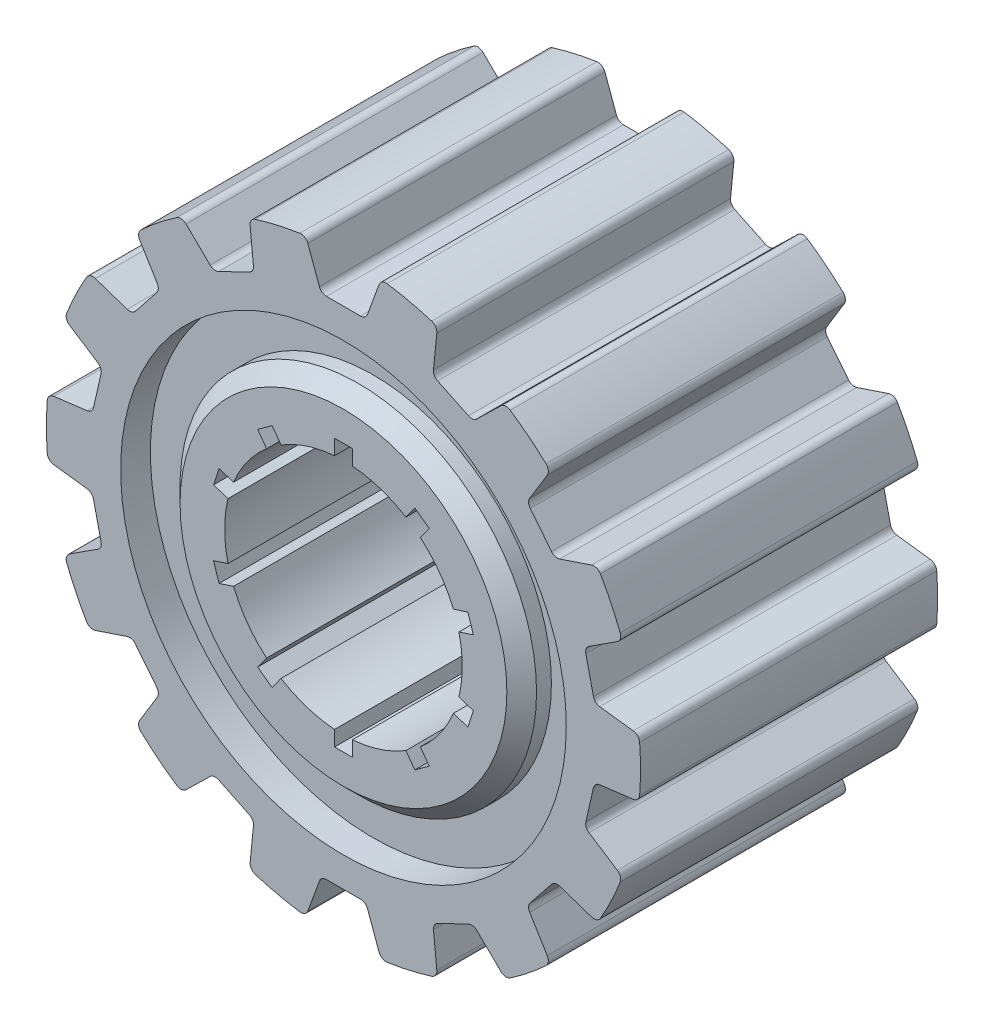
from build123d import *

# Parameters (mm, degrees)
SKETCH1_R           = 10
BOSS_EXTRUDE1_DEPTH = 10
CUT_EXTRUDE1_START  = -11
CUT_EXTRUDE1_DEPTH  = 12
CIRPATTERN1_COUNT   = 14
CUT_EXTRUDE2_START  = -4
SKETCH3_R           = 7.5
SKETCH3_R_2         = 6
CUT_EXTRUDE2_DEPTH  = 2
CHAMFER1_SIZE       = 0.5
CHAMFER2_SIZE       = 0.5
FILLET1_R           = 0.25


with BuildPart() as part:
    # Sketch1 → Boss-Extrude1 (new body)
    with BuildSketch(Plane.XY):
        Circle(SKETCH1_R)
        with BuildLine():
            Line((2.887738734, 3.464240899), (2.402328537, 3.81691205))
            Line((2.402328537, 3.81691205), (2.101814002, 3.403289277))
            ThreePointArc((2.101814002, 3.403289277), (1.236067977, 3.804226065), (0.3, 3.988734135))
            Line((0.3, 3.988734135), (0.3, 4.5))
            Line((0.3, 4.5), (-0.3, 4.5))
            Line((-0.3, 4.5), (-0.3, 3.988734135))
            ThreePointArc((-0.3, 3.988734135), (-1.236067978, 3.804226065), (-2.101814002, 3.403289277))
            Line((-2.101814002, 3.403289277), (-2.402328537, 3.81691205))
            Line((-2.402328537, 3.81691205), (-2.887738734, 3.464240899))
            Line((-2.887738734, 3.464240899), (-2.587224198, 3.050618126))
            ThreePointArc((-2.587224198, 3.050618126), (-3.236067977, 2.351141009), (-3.700806493, 1.517903589))
            Line((-3.700806493, 1.517903589), (-4.187049225, 1.67589343))
            Line((-4.187049225, 1.67589343), (-4.372459422, 1.10525952))
            Line((-4.372459422, 1.10525952), (-3.886216689, 0.947269679))
            ThreePointArc((-3.886216689, 0.947269679), (-4, 0), (-3.886216689, -0.947269679))
            Line((-3.886216689, -0.947269679), (-4.372459422, -1.10525952))
            Line((-4.372459422, -1.10525952), (-4.187049225, -1.67589343))
            Line((-4.187049225, -1.67589343), (-3.700806493, -1.517903589))
            ThreePointArc((-3.700806493, -1.517903589), (-3.236067977, -2.351141009), (-2.587224198, -3.050618126))
            Line((-2.587224198, -3.050618126), (-2.887738734, -3.464240899))
            Line((-2.887738734, -3.464240899), (-2.402328537, -3.81691205))
            Line((-2.402328537, -3.81691205), (-2.101814002, -3.403289277))
            ThreePointArc((-2.101814002, -3.403289277), (-1.236067977, -3.804226065), (-0.3, -3.988734135))
            Line((-0.3, -3.988734135), (-0.3, -4.5))
            Line((-0.3, -4.5), (0.3, -4.5))
            Line((0.3, -4.5), (0.3, -3.988734135))
            ThreePointArc((0.3, -3.988734135), (1.236067978, -3.804226065), (2.101814002, -3.403289277))
            Line((2.101814002, -3.403289277), (2.402328537, -3.81691205))
            Line((2.402328537, -3.81691205), (2.887738734, -3.464240899))
            Line((2.887738734, -3.464240899), (2.587224198, -3.050618126))
            ThreePointArc((2.587224198, -3.050618126), (3.236067977, -2.351141009), (3.700806493, -1.517903589))
            Line((3.700806493, -1.517903589), (4.187049225, -1.67589343))
            Line((4.187049225, -1.67589343), (4.372459422, -1.10525952))
            Line((4.372459422, -1.10525952), (3.886216689, -0.947269679))
            ThreePointArc((3.886216689, -0.947269679), (4, 0), (3.886216689, 0.947269679))
            Line((3.886216689, 0.947269679), (4.372459422, 1.10525952))
            Line((4.372459422, 1.10525952), (4.187049225, 1.67589343))
            Line((4.187049225, 1.67589343), (3.700806493, 1.517903589))
            ThreePointArc((3.700806493, 1.517903589), (3.236067977, 2.351141009), (2.587224198, 3.050618126))
            Line((2.587224198, 3.050618126), (2.887738734, 3.464240899))
        make_face(mode=Mode.SUBTRACT)
    extrude(amount=BOSS_EXTRUDE1_DEPTH)

    # Sketch2 → Cut-Extrude1 (cut)
    with BuildSketch(Plane.XY.offset(10).offset(CUT_EXTRUDE1_START)):
        Polygon((-20.341084154, 62.326061337), (-1.266640021, 9.919456792), (-0.75, 8.5), (0.75, 8.5), (1.266640021, 9.919456792), (20.341084154, 62.326061337), (20.341084154, 173.86594871), (-20.341084154, 173.86594871), align=None)
    cut_extrude1 = extrude(amount=CUT_EXTRUDE1_DEPTH, mode=Mode.SUBTRACT)

    # CirPattern1: Cut-Extrude1 ×14 about axis
    cirpattern1_axis = Axis((0, 0, 0), (0, 0, 1))
    for i in range(1, CIRPATTERN1_COUNT):
        add(cut_extrude1.rotate(cirpattern1_axis, i * 360 / CIRPATTERN1_COUNT), mode=Mode.SUBTRACT)

    # Sketch3 → Cut-Extrude2 (cut, through all)
    with BuildSketch(Plane.XY.offset(5).offset(CUT_EXTRUDE2_START)):
        Circle(SKETCH3_R)
        Circle(SKETCH3_R_2, mode=Mode.SUBTRACT)
    cut_extrude2 = extrude(amount=-CUT_EXTRUDE2_DEPTH, mode=Mode.SUBTRACT)

    # Chamfer1
    chamfer1_edges = [part.edges().sort_by_distance(p)[0] for p in [
        (-6, 0, 0),
    ]]
    chamfer(chamfer1_edges, length=CHAMFER1_SIZE)

    # Mirror2: Cut-Extrude2 across plane
    add(cut_extrude2.mirror(Plane.XY.offset(5)), mode=Mode.SUBTRACT)

    # Chamfer2
    chamfer2_edges = [part.edges().sort_by_distance(p)[0] for p in [
        (-6, 0, 10),
    ]]
    chamfer(chamfer2_edges, length=CHAMFER2_SIZE)

    # Fillet1
    fillet1_edges = [part.edges().sort_by_distance(p)[0] for p in [
        (0.75, 8.5, 5),
        (-0.75, 8.5, 5),
        (-1.266640021, 9.919456792, 5),
        (1.266640021, 9.919456792, 5),
        (-3.162687777, 9.486696265, 5),
        (-5.445094229, 8.387547248, 5),
        (5.445094229, 8.387547248, 5),
        (3.162687777, 9.486696265, 5),
        (8.545080745, 5.194381104, 5),
        (6.965606473, 7.174979196, 5),
        (9.952609221, 0.972404078, 5),
        (9.38890138, 3.442169501, 5),
        (9.38890138, -3.442169501, 5),
        (9.952609221, -0.972404078, 5),
        (6.965606473, -7.174979196, 5),
        (8.545080745, -5.194381104, 5),
        (3.162687777, -9.486696265, 5),
        (5.445094229, -8.387547248, 5),
        (-1.266640021, -9.919456792, 5),
        (1.266640021, -9.919456792, 5),
        (-5.445094229, -8.387547248, 5),
        (-3.162687777, -9.486696265, 5),
        (-8.545080745, -5.194381104, 5),
        (-6.965606473, -7.174979196, 5),
        (-9.952609221, -0.972404078, 5),
        (-9.38890138, -3.442169501, 5),
        (-9.38890138, 3.442169501, 5),
        (-9.952609221, 0.972404078, 5),
        (-6.965606473, 7.174979196, 5),
        (-8.545080745, 5.194381104, 5),
        (-6.17795025, 5.886036928, 5),
        (-7.113184952, 4.713289704, 5),
        (-8.119996553, 2.622623873, 5),
        (-8.453777954, 1.160232004, 5),
        (-8.453777954, -1.160232004, 5),
        (-8.119996553, -2.622623873, 5),
        (-7.113184952, -4.713289704, 5),
        (-6.17795025, -5.886036928, 5),
        (-4.363738433, -7.332822573, 5),
        (-3.012285132, -7.983648182, 5),
        (-0.75, -8.5, 5),
        (0.75, -8.5, 5),
        (3.012285132, -7.983648182, 5),
        (4.363738433, -7.332822573, 5),
        (6.17795025, -5.886036928, 5),
        (7.113184952, -4.713289704, 5),
        (8.119996553, -2.622623873, 5),
        (8.453777954, -1.160232004, 5),
        (8.453777954, 1.160232004, 5),
        (8.119996553, 2.622623873, 5),
        (7.113184952, 4.713289704, 5),
        (6.17795025, 5.886036928, 5),
        (4.363738433, 7.332822573, 5),
        (3.012285132, 7.983648182, 5),
        (-3.012285132, 7.983648182, 5),
        (-4.363738433, 7.332822573, 5),
    ]]
    fillet(fillet1_edges, radius=FILLET1_R)


solid = part.part
